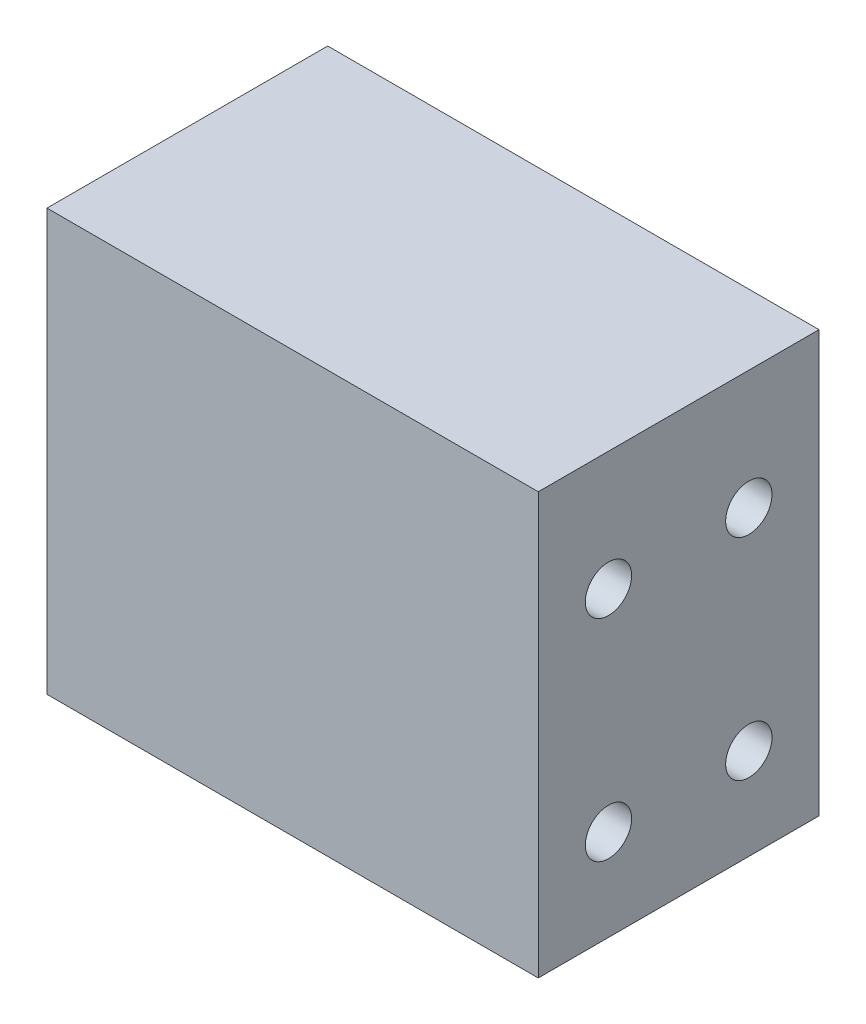
from build123d import *

# Parameters (mm, degrees)
SKETCH1_W                      = 35
SKETCH1_H                      = 30
BOSS_EXTRUDE1_DEPTH            = 20
M4X0_7_TAPPED_HOLE1_AT_2_COUNT = 2
M4X0_7_TAPPED_HOLE1_AT_2_PITCH = 18.027756377
M4X0_7_TAPPED_HOLE1_AT_3_COUNT = 2
M4X0_7_TAPPED_HOLE1_AT_3_PITCH = 15
M4X0_7_TAPPED_HOLE1_AT_4_COUNT = 2
M4X0_7_TAPPED_HOLE1_AT_4_PITCH = 10


with BuildPart() as part:
    # Sketch1 → Boss-Extrude1 (new body)
    with BuildSketch(Plane.XY):
        with Locations((-17.5, 15)):
            Rectangle(SKETCH1_W, SKETCH1_H)
    extrude(amount=BOSS_EXTRUDE1_DEPTH)

    # Sketch6 → M4x0.7 Tapped Hole1 (revolve, cut)
    with BuildSketch(Plane(origin=(-35, 21.5125, 5), x_dir=(0, 0, 1), z_dir=(0, 1, 0))):
        Polygon((0, 0), (0, 14.491420021), (1.65, 13.5), (1.65, 0), align=None)
    m4x0_7_tapped_hole1 = revolve(axis=Axis((-41.35, 21.5125, 5), (1, 0, 0)), mode=Mode.SUBTRACT)

    # M4x0.7 Tapped Hole1 at 2: M4x0.7 Tapped Hole1 ×2
    with Locations(*[Vector(0, -0.832050294, 0.554700196) * (i * M4X0_7_TAPPED_HOLE1_AT_2_PITCH) for i in range(1, M4X0_7_TAPPED_HOLE1_AT_2_COUNT)]):
        add(m4x0_7_tapped_hole1, mode=Mode.SUBTRACT)

    # M4x0.7 Tapped Hole1 at 3: M4x0.7 Tapped Hole1 ×2
    with Locations(*[(0, -i * M4X0_7_TAPPED_HOLE1_AT_3_PITCH, 0) for i in range(1, M4X0_7_TAPPED_HOLE1_AT_3_COUNT)]):
        add(m4x0_7_tapped_hole1, mode=Mode.SUBTRACT)

    # M4x0.7 Tapped Hole1 at 4: M4x0.7 Tapped Hole1 ×2
    with Locations(*[(0, 0, i * M4X0_7_TAPPED_HOLE1_AT_4_PITCH) for i in range(1, M4X0_7_TAPPED_HOLE1_AT_4_COUNT)]):
        add(m4x0_7_tapped_hole1, mode=Mode.SUBTRACT)

    # Mirror1: M4x0.7 Tapped Hole1 across plane
    add(m4x0_7_tapped_hole1.mirror(Plane.ZY.offset(17.5)), mode=Mode.SUBTRACT)

    # Mirror1 copy 1 sketch → Mirror1 copy 1 (revolve, cut)
    with BuildSketch(Plane(origin=(0, 6.5125, 15), x_dir=(0, 0, 1), z_dir=(0, 1, 0))):
        Polygon((0, 0), (0, -14.491420021), (1.65, -13.5), (1.65, 0), align=None)
    revolve(axis=Axis((6.35, 6.5125, 15), (1, 0, 0)), mode=Mode.SUBTRACT)

    # Mirror1 copy 2 sketch → Mirror1 copy 2 (revolve, cut)
    with BuildSketch(Plane(origin=(0, 6.5125, 5), x_dir=(0, 0, 1), z_dir=(0, 1, 0))):
        Polygon((0, 0), (0, -14.491420021), (1.65, -13.5), (1.65, 0), align=None)
    revolve(axis=Axis((6.35, 6.5125, 5), (1, 0, 0)), mode=Mode.SUBTRACT)

    # Mirror1 copy 3 sketch → Mirror1 copy 3 (revolve, cut)
    with BuildSketch(Plane(origin=(0, 21.5125, 15), x_dir=(0, 0, 1), z_dir=(0, 1, 0))):
        Polygon((0, 0), (0, -14.491420021), (1.65, -13.5), (1.65, 0), align=None)
    revolve(axis=Axis((6.35, 21.5125, 15), (1, 0, 0)), mode=Mode.SUBTRACT)


solid = part.part
